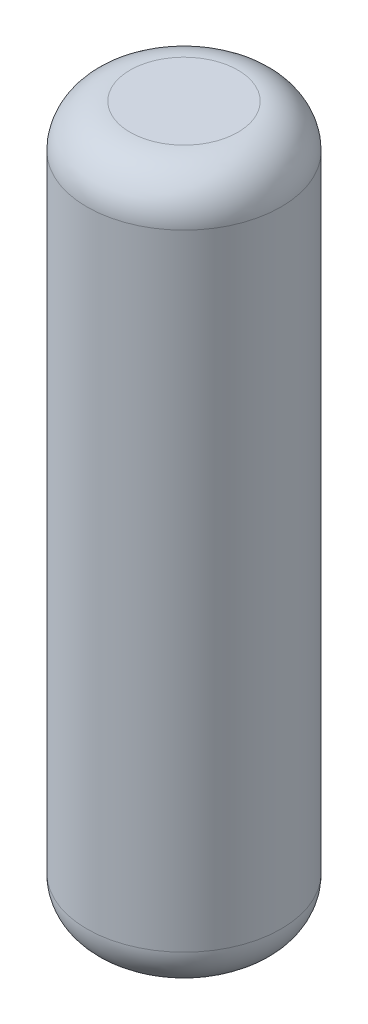
from build123d import *

# Parameters (mm, degrees)
SKETCH1_R           = 2.25
BOSS_EXTRUDE1_DEPTH = 16.5
FILLET2_R           = 1


with BuildPart() as part:
    # Sketch1 → Boss-Extrude1 (new body)
    with BuildSketch(Plane(origin=(0, 0, 0), x_dir=(1, 0, 0), z_dir=(0, 1, 0))):
        Circle(SKETCH1_R)
    extrude(amount=BOSS_EXTRUDE1_DEPTH)

    # Fillet2
    fillet2_edges = [part.edges().sort_by_distance(p)[0] for p in [
        (-2.25, 0, 0),
        (-2.25, 16.5, 0),
    ]]
    fillet(fillet2_edges, radius=FILLET2_R)


solid = part.part
